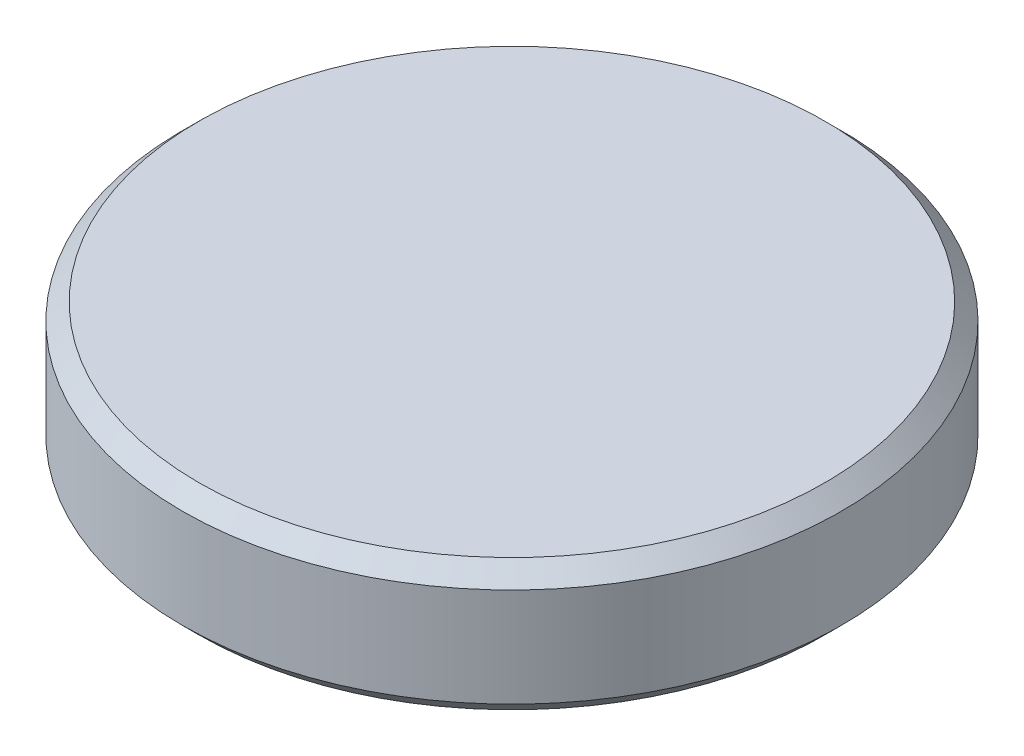
from build123d import *

# Parameters (mm, degrees)
SKETCH_1_R      = 5
EXTRUDE_1_DEPTH = 2
CHAMFER_1_SIZE  = 0.25


with BuildPart() as part:
    # ｽｹｯﾁ1 → ﾎﾞｽ - 押し出し1 (new body)
    with BuildSketch(Plane(origin=(0, 0, 0), x_dir=(1, 0, 0), z_dir=(0, 1, 0))):
        Circle(SKETCH_1_R)
    extrude(amount=EXTRUDE_1_DEPTH)

    # 面取り1
    chamfer_1_edges = [part.edges().sort_by_distance(p)[0] for p in [
        (-5, 0, 0),
        (-5, 2, 0),
    ]]
    chamfer(chamfer_1_edges, length=CHAMFER_1_SIZE)


solid = part.part
